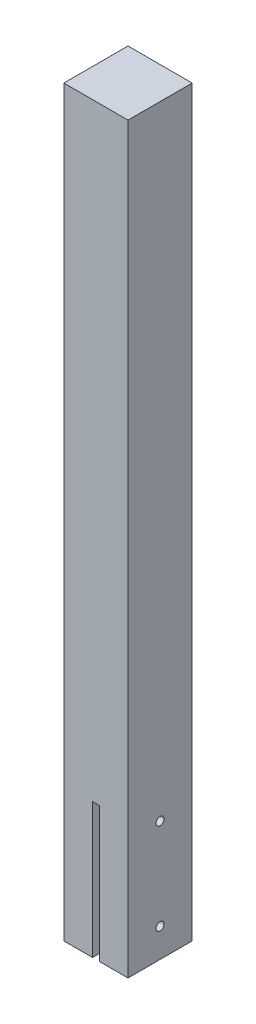
from build123d import *

# Parameters (mm, degrees)
SKETCH2_W                                   = 95
SKETCH2_H                                   = 95
EXTRUDE_H_JD_DEPTH                          = 1100
SKETCH10_W                                  = 10
SKETCH10_H                                  = 95
CUT_SLITS_F_R_STOLPFOT_DEPTH                = 200
CUT_SKRUVH_L_F_R_STOLPFOT_REACH             = 49.5
SKETCH8_R                                   = 6
CUT_SKRUVH_L_F_R_STOLPFOT_DIRECTION_2_REACH = 49.5


with BuildPart() as part:
    # Sketch2 → Extrude h_jd (new body)
    with BuildSketch(Plane(origin=(0, 0, 0), x_dir=(1, 0, 0), z_dir=(0, 1, 0))):
        Rectangle(SKETCH2_W, SKETCH2_H)
    extrude(amount=EXTRUDE_H_JD_DEPTH)

    # Sketch10 → Cut-slits f_r stolpfot (cut)
    with BuildSketch(Plane(origin=(0, 0, 0), x_dir=(-1, 0, 0), z_dir=(0, -1, 0))):
        Rectangle(SKETCH10_W, SKETCH10_H)
    extrude(amount=-CUT_SLITS_F_R_STOLPFOT_DEPTH, mode=Mode.SUBTRACT)

    # Sketch8 → Cut-skruvh_l f_r stolpfot (cut, up to next)
    with BuildSketch(Plane(origin=(0, -97.5, 0), x_dir=(0, 1, 0), z_dir=(-1, 0, 0)), mode=Mode.PRIVATE) as cut_skruvh_l_f_r_stolpfot_sk1:
        with Locations(Location((275, 0, 0), (0, 0, 270))):  # turned: the seam where the file's is
            Circle(SKETCH8_R)
    cut_skruvh_l_f_r_stolpfot_tool1 = extrude(cut_skruvh_l_f_r_stolpfot_sk1.sketch, amount=CUT_SKRUVH_L_F_R_STOLPFOT_REACH, mode=Mode.PRIVATE) & part.part
    add(cut_skruvh_l_f_r_stolpfot_tool1.solids().sort_by_distance((0, 177.5, 0))[0], mode=Mode.SUBTRACT)
    # Sketch8 → Cut-skruvh_l f_r stolpfot (cut, up to next)
    with BuildSketch(Plane(origin=(0, -97.5, 0), x_dir=(0, 1, 0), z_dir=(-1, 0, 0)), mode=Mode.PRIVATE) as cut_skruvh_l_f_r_stolpfot_sk2:
        with Locations(Location((140, 0, 0), (0, 0, 270))):  # turned: the seam where the file's is
            Circle(SKETCH8_R)
    cut_skruvh_l_f_r_stolpfot_tool2 = extrude(cut_skruvh_l_f_r_stolpfot_sk2.sketch, amount=CUT_SKRUVH_L_F_R_STOLPFOT_REACH, mode=Mode.PRIVATE) & part.part
    add(cut_skruvh_l_f_r_stolpfot_tool2.solids().sort_by_distance((0, 42.5, 0))[0], mode=Mode.SUBTRACT)

    # Sketch8 → Cut-skruvh_l f_r stolpfot direction 2 (cut, up to next)
    with BuildSketch(Plane(origin=(0, -97.5, 0), x_dir=(0, 1, 0), z_dir=(-1, 0, 0)), mode=Mode.PRIVATE) as cut_skruvh_l_f_r_stolpfot_direction_2_sk1:
        with Locations(Location((275, 0, 0), (0, 0, 270))):  # turned: the seam where the file's is
            Circle(SKETCH8_R)
    cut_skruvh_l_f_r_stolpfot_direction_2_tool1 = extrude(cut_skruvh_l_f_r_stolpfot_direction_2_sk1.sketch, amount=-CUT_SKRUVH_L_F_R_STOLPFOT_DIRECTION_2_REACH, mode=Mode.PRIVATE) & part.part
    add(cut_skruvh_l_f_r_stolpfot_direction_2_tool1.solids().sort_by_distance((0, 177.5, 0))[0], mode=Mode.SUBTRACT)
    # Sketch8 → Cut-skruvh_l f_r stolpfot direction 2 (cut, up to next)
    with BuildSketch(Plane(origin=(0, -97.5, 0), x_dir=(0, 1, 0), z_dir=(-1, 0, 0)), mode=Mode.PRIVATE) as cut_skruvh_l_f_r_stolpfot_direction_2_sk2:
        with Locations(Location((140, 0, 0), (0, 0, 270))):  # turned: the seam where the file's is
            Circle(SKETCH8_R)
    cut_skruvh_l_f_r_stolpfot_direction_2_tool2 = extrude(cut_skruvh_l_f_r_stolpfot_direction_2_sk2.sketch, amount=-CUT_SKRUVH_L_F_R_STOLPFOT_DIRECTION_2_REACH, mode=Mode.PRIVATE) & part.part
    add(cut_skruvh_l_f_r_stolpfot_direction_2_tool2.solids().sort_by_distance((0, 42.5, 0))[0], mode=Mode.SUBTRACT)


solid = part.part
